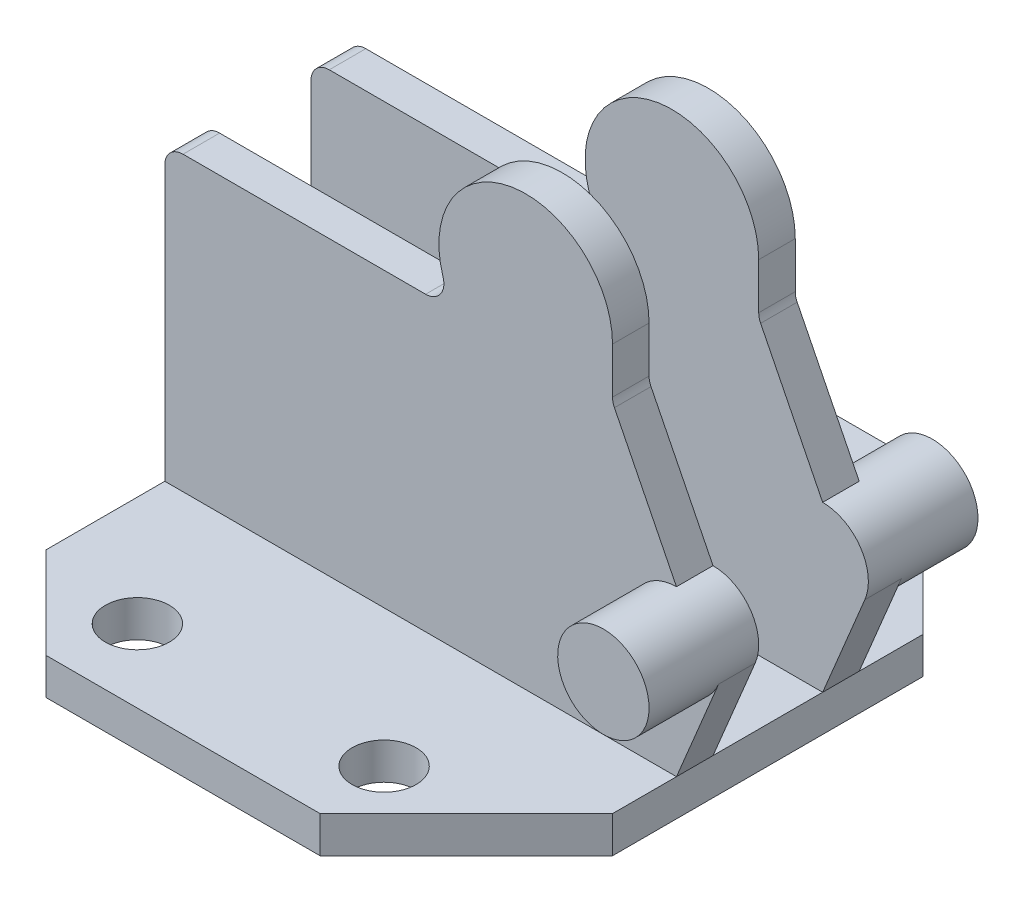
from build123d import *

# Parameters (mm, degrees)
SKETCH1_R           = 3.5
BOSS_EXTRUDE1_DEPTH = 4
BOSS_EXTRUDE2_DEPTH = 4
SKETCH6_R           = 5
BOSS_EXTRUDE3_DEPTH = 12


with BuildPart() as part:
    # Sketch1 → Boss-Extrude1 (new body)
    with BuildSketch(Plane(origin=(0, 0, 0), x_dir=(1, 0, 0), z_dir=(0, 1, 0))):
        Polygon((-28, 23), (-18, 33), (12, 33), (28, 17), (28, -17), (12, -33), (-18, -33), (-28, -23), align=None)
        with Locations((11, 25)):
            Circle(SKETCH1_R, mode=Mode.SUBTRACT)
        with Locations((11, -25)):
            Circle(SKETCH1_R, mode=Mode.SUBTRACT)
        with Locations((-16, -25)):
            Circle(SKETCH1_R, mode=Mode.SUBTRACT)
        with Locations((-16, 25)):
            Circle(SKETCH1_R, mode=Mode.SUBTRACT)
    extrude(amount=BOSS_EXTRUDE1_DEPTH)

    # Sketch2 → Boss-Extrude2 (add)
    with BuildSketch(Plane.XY.offset(6)):
        with BuildLine():
            Line((-28, 34), (-28, 4))
            Line((-28, 4), (28, 4))
            Line((28, 4), (32.615384615, 15.076923077))
            ThreePointArc((32.615384615, 15.076923077), (23.839748528, 14.226499019), (28, 22))
            Line((28, 22), (21.211145618, 35.577708764))
            ThreePointArc((21.211145618, 35.577708764), (21.053502021, 36.012630114), (21, 36.472135955))
            Line((21, 36.472135955), (21, 41.5))
            ThreePointArc((21, 41.5), (10.03689158, 50.886656154), (2.450670789, 38.608695652))
            ThreePointArc((2.450670789, 38.608695652), (2.160694556, 36.820464351), (0.54554885, 36))
            Line((0.54554885, 36), (-26, 36))
            ThreePointArc((-26, 36), (-27.414213562, 35.414213562), (-28, 34))
        make_face()
    boss_extrude2 = extrude(amount=BOSS_EXTRUDE2_DEPTH)

    # Sketch6 → Boss-Extrude3 (add)
    with BuildSketch(Plane.XY.offset(6)):
        with Locations((28, 17)):
            Circle(SKETCH6_R)
    boss_extrude3 = extrude(amount=BOSS_EXTRUDE3_DEPTH)

    # Mirror1: Boss-Extrude2 across plane
    add(boss_extrude2.mirror(Plane.XY))

    # Mirror2: Boss-Extrude3 across plane
    add(boss_extrude3.mirror(Plane.XY))


solid = part.part
